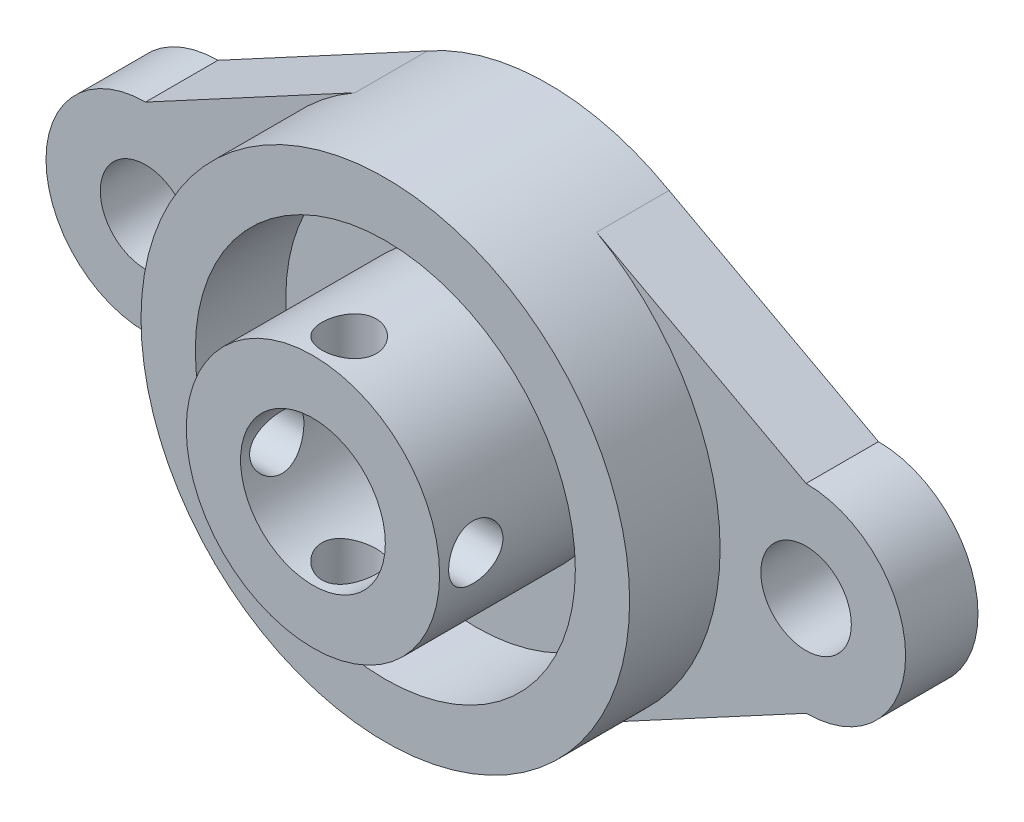
from build123d import *

# Parameters (mm, degrees)
ESBO_O1_R                  = 2.5
ESBO_O1_R_2                = 4
RESSALTO_EXTRUS_O1_DEPTH   = 4
ESBO_O2_R                  = 13.5
ESBO_O2_R_2                = 10.5
RESSALTO_EXTRUS_O2_DEPTH   = 5
ESBO_O3_R                  = 7
ESBO_O3_R_2                = 4
RESSALTO_EXTRUS_O3_DEPTH   = 9
ESBO_O4_R                  = 1.5
CORTE_EXTRUS_O1_DEPTH      = 14.5
CORTE_EXTRUS_O1_DEPTH_BACK = 14.5
ESBO_O5_R                  = 1.5
CORTE_EXTRUS_O2_DEPTH      = 24.75
CORTE_EXTRUS_O2_DEPTH_BACK = 24.75


with BuildPart() as part:
    # Esboço1 → Ressalto-extrusão1 (new body)
    with BuildSketch(Plane.XY):
        with BuildLine():
            Line((-18.25, 5.5), (-6.677721963, 11.73277586))
            ThreePointArc((-6.677721963, 11.73277586), (0, 13.5), (6.677721963, 11.73277586))
            Line((6.677721963, 11.73277586), (18.25, 5.5))
            ThreePointArc((18.25, 5.5), (23.75, 0), (18.25, -5.5))
            Line((18.25, -5.5), (6.677721963, -11.73277586))
            ThreePointArc((6.677721963, -11.73277586), (0, -13.5), (-6.677721963, -11.73277586))
            Line((-6.677721963, -11.73277586), (-18.25, -5.5))
            ThreePointArc((-18.25, -5.5), (-23.75, 0), (-18.25, 5.5))
        make_face()
        with Locations((-18.25, 0)):
            Circle(ESBO_O1_R, mode=Mode.SUBTRACT)
        with Locations((18.25, 0)):
            Circle(ESBO_O1_R, mode=Mode.SUBTRACT)
        Circle(ESBO_O1_R_2, mode=Mode.SUBTRACT)
    extrude(amount=RESSALTO_EXTRUS_O1_DEPTH)

    # Esboço2 → Ressalto-extrusão2 (add)
    with BuildSketch(Plane.XY.offset(4)):
        Circle(ESBO_O2_R)
        Circle(ESBO_O2_R_2, mode=Mode.SUBTRACT)
    extrude(amount=RESSALTO_EXTRUS_O2_DEPTH)

    # Esboço3 → Ressalto-extrusão3 (add)
    with BuildSketch(Plane.XY.offset(4)):
        Circle(ESBO_O3_R)
        Circle(ESBO_O3_R_2, mode=Mode.SUBTRACT)
    extrude(amount=RESSALTO_EXTRUS_O3_DEPTH)

    # Esboço4 → Corte-extrusão1 (cut, two sides)
    with BuildSketch(Plane(origin=(0, 0, 0), x_dir=(1, 0, 0), z_dir=(0, 1, 0))) as corte_extrus_o1_sk:
        with Locations((0, -11)):
            Circle(ESBO_O4_R)
    extrude(amount=CORTE_EXTRUS_O1_DEPTH, mode=Mode.SUBTRACT)
    extrude(corte_extrus_o1_sk.sketch, amount=-CORTE_EXTRUS_O1_DEPTH_BACK, mode=Mode.SUBTRACT)

    # Esboço5 → Corte-extrusão2 (cut, two sides)
    with BuildSketch(Plane(origin=(0, 0, 0), x_dir=(0, 0, -1), z_dir=(1, 0, 0))) as corte_extrus_o2_sk:
        with Locations((-11, 0)):
            Circle(ESBO_O5_R)
    extrude(amount=CORTE_EXTRUS_O2_DEPTH, mode=Mode.SUBTRACT)
    extrude(corte_extrus_o2_sk.sketch, amount=-CORTE_EXTRUS_O2_DEPTH_BACK, mode=Mode.SUBTRACT)


solid = part.part
